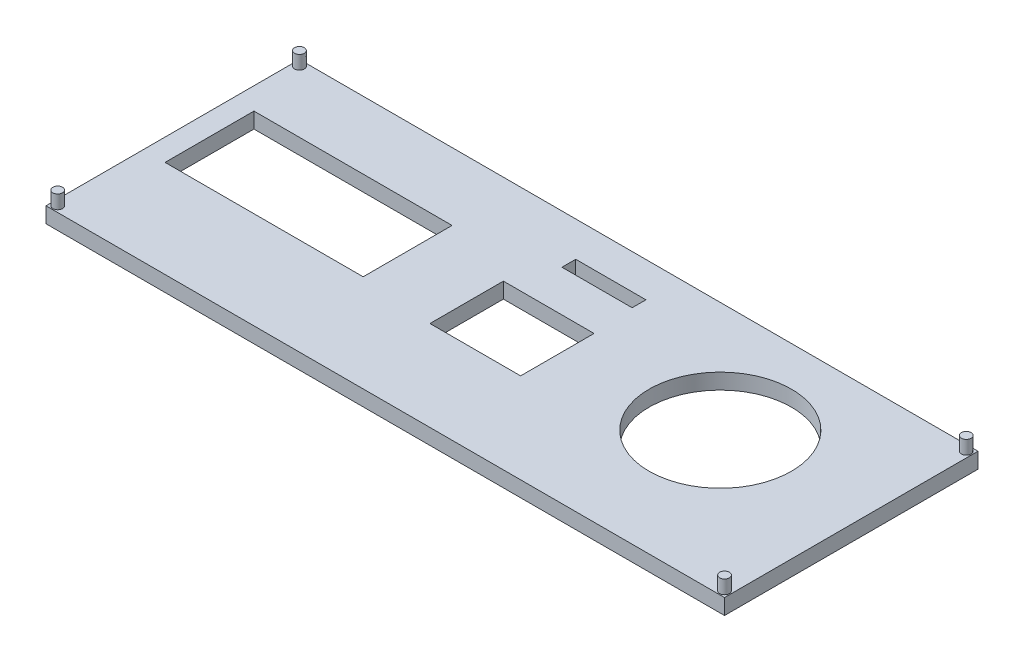
from build123d import *

# Parameters (mm, degrees)
SKETCH1_W           = 174
SKETCH1_H           = 65
BOSS_EXTRUDE1_DEPTH = 4
SKETCH2_R           = 18.25
CUT_EXTRUDE1_DEPTH  = 4
SKETCH4_W           = 50.8
SKETCH4_H           = 22.8
CUT_EXTRUDE2_DEPTH  = 4
SKETCH5_W           = 18
SKETCH5_H           = 3.531440261
CUT_EXTRUDE3_DEPTH  = 4
SKETCH9_W           = 23.248648384
SKETCH9_H           = 18.834348058
CUT_EXTRUDE4_DEPTH  = 4
SKETCH10_R          = 1.25
BOSS_EXTRUDE2_DEPTH = 3.5
SKETCH12_R          = 1.25
BOSS_EXTRUDE3_DEPTH = 3.5


with BuildPart() as part:
    # Sketch1 → Boss-Extrude1 (new body)
    with BuildSketch(Plane(origin=(0, 0, 0), x_dir=(1, 0, 0), z_dir=(0, 1, 0))):
        Rectangle(SKETCH1_W, SKETCH1_H)
    extrude(amount=BOSS_EXTRUDE1_DEPTH)

    # Sketch2 → Cut-Extrude1 (cut)
    with BuildSketch(Plane(origin=(0, 4, 0), x_dir=(1, 0, 0), z_dir=(0, 1, 0))):
        with Locations((49.293020306, 4.120013638)):
            Circle(SKETCH2_R)
    extrude(amount=-CUT_EXTRUDE1_DEPTH, mode=Mode.SUBTRACT)

    # Sketch4 → Cut-Extrude2 (cut)
    with BuildSketch(Plane(origin=(0, 4, 0), x_dir=(1, 0, 0), z_dir=(0, 1, 0))):
        with Locations((-55.970269341, 3.8)):
            Rectangle(SKETCH4_W, SKETCH4_H)
    extrude(amount=-CUT_EXTRUDE2_DEPTH, mode=Mode.SUBTRACT)

    # Sketch5 → Cut-Extrude3 (cut)
    with BuildSketch(Plane(origin=(0, 4, 0), x_dir=(1, 0, 0), z_dir=(0, 1, 0))):
        with Locations((1.8, 21.777214942)):
            Rectangle(SKETCH5_W, SKETCH5_H)
    extrude(amount=-CUT_EXTRUDE3_DEPTH, mode=Mode.SUBTRACT)

    # Sketch9 → Cut-Extrude4 (cut)
    with BuildSketch(Plane(origin=(0, 4, 0), x_dir=(1, 0, 0), z_dir=(0, 1, 0))):
        Rectangle(SKETCH9_W, SKETCH9_H)
    extrude(amount=-CUT_EXTRUDE4_DEPTH, mode=Mode.SUBTRACT)

    # Sketch10 → Boss-Extrude2 (add)
    with BuildSketch(Plane(origin=(0, 4, 0), x_dir=(1, 0, 0), z_dir=(0, 1, 0))):
        with Locations((-85.5, 31)):
            Circle(SKETCH10_R)
        with Locations((-85.5, -31)):
            Circle(SKETCH10_R)
    extrude(amount=BOSS_EXTRUDE2_DEPTH)

    # Sketch12 → Boss-Extrude3 (add)
    with BuildSketch(Plane(origin=(0, 4, 0), x_dir=(1, 0, 0), z_dir=(0, 1, 0))):
        with Locations((85.5, 31)):
            Circle(SKETCH12_R)
        with Locations((85.5, -31)):
            Circle(SKETCH12_R)
    extrude(amount=BOSS_EXTRUDE3_DEPTH)


solid = part.part
